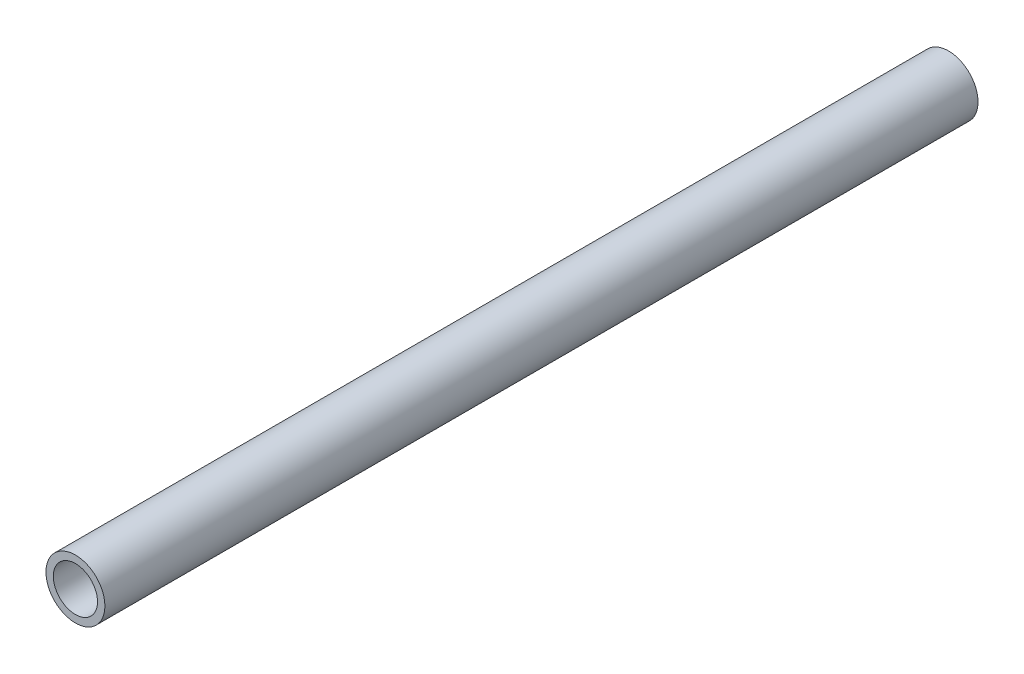
from build123d import *

# Parameters (mm, degrees)
SKETCH_1_R      = 8
SKETCH_1_R_2    = 6
EXTRUDE_1_DEPTH = 237


with BuildPart() as part:
    # 草图1 → 凸台-拉伸1 (new body)
    with BuildSketch(Plane.XY):
        Circle(SKETCH_1_R)
        Circle(SKETCH_1_R_2, mode=Mode.SUBTRACT)
    extrude(amount=EXTRUDE_1_DEPTH)


solid = part.part
